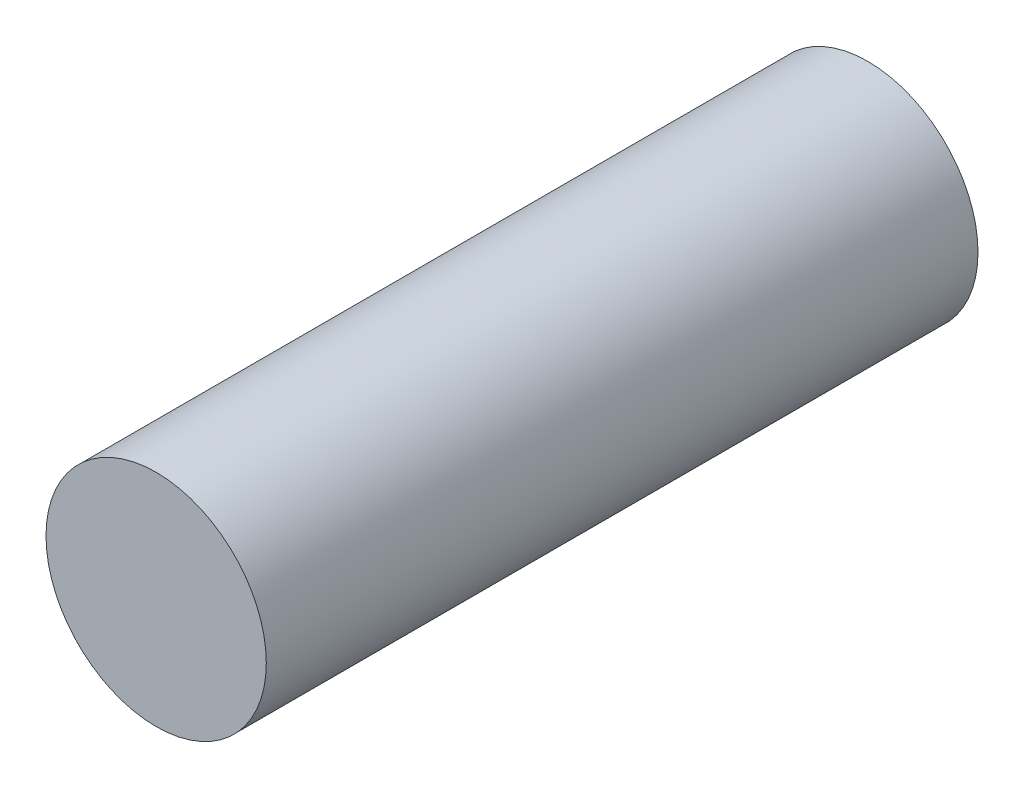
from build123d import *

# Parameters (mm, degrees)
SKETCH1_W = 105
SKETCH1_H = 16.25


with BuildPart() as part:
    # Sketch1 → Revolve1 (revolve)
    with BuildSketch(Plane(origin=(0, 0, 0), x_dir=(0, 0, -1), z_dir=(1, 0, 0))):
        with Locations((0, 8.125)):
            Rectangle(SKETCH1_W, SKETCH1_H)
    revolve(axis=Axis((0, 0, 0), (0, 0, -1)))


solid = part.part
